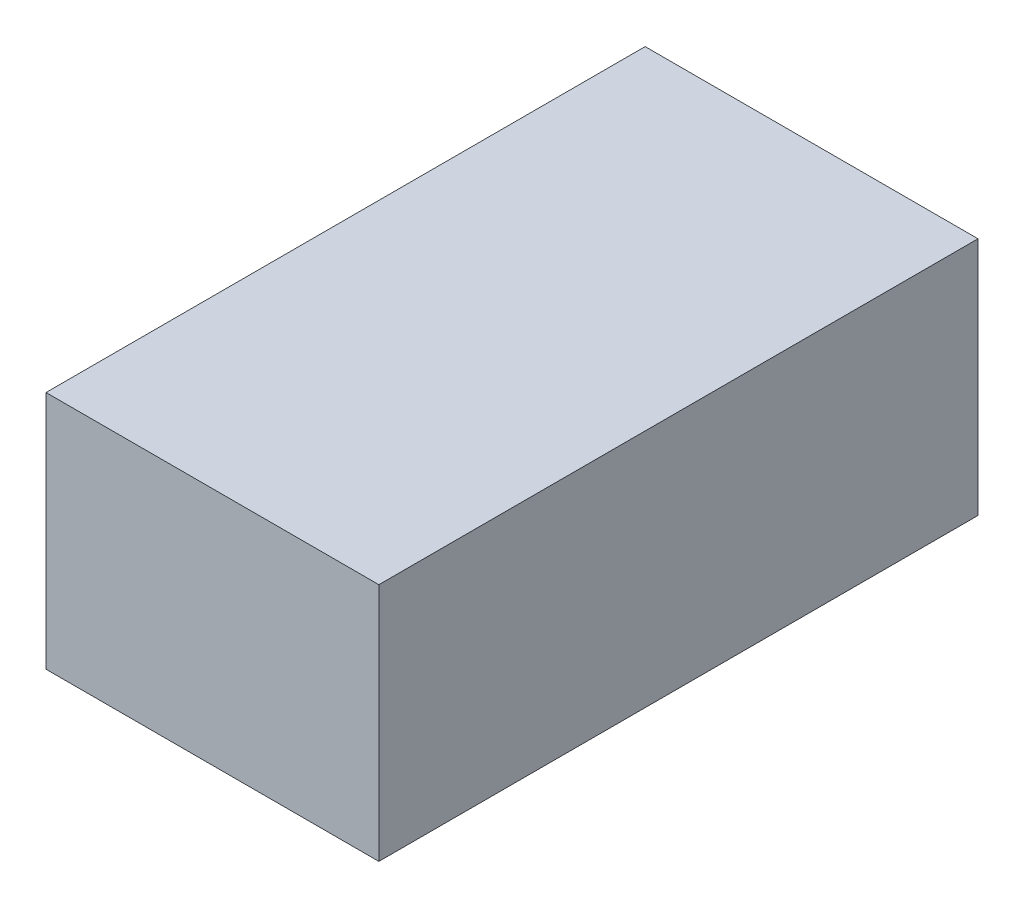
from build123d import *

# Parameters (mm, degrees)
SKETCH1_W           = 25
SKETCH1_H           = 45
BOSS_EXTRUDE1_DEPTH = 18


with BuildPart() as part:
    # Sketch1 → Boss-Extrude1 (new body)
    with BuildSketch(Plane(origin=(0, 0, 0), x_dir=(1, 0, 0), z_dir=(0, 1, 0))):
        with Locations((12.5, -22.5)):
            Rectangle(SKETCH1_W, SKETCH1_H)
    extrude(amount=BOSS_EXTRUDE1_DEPTH)


solid = part.part
